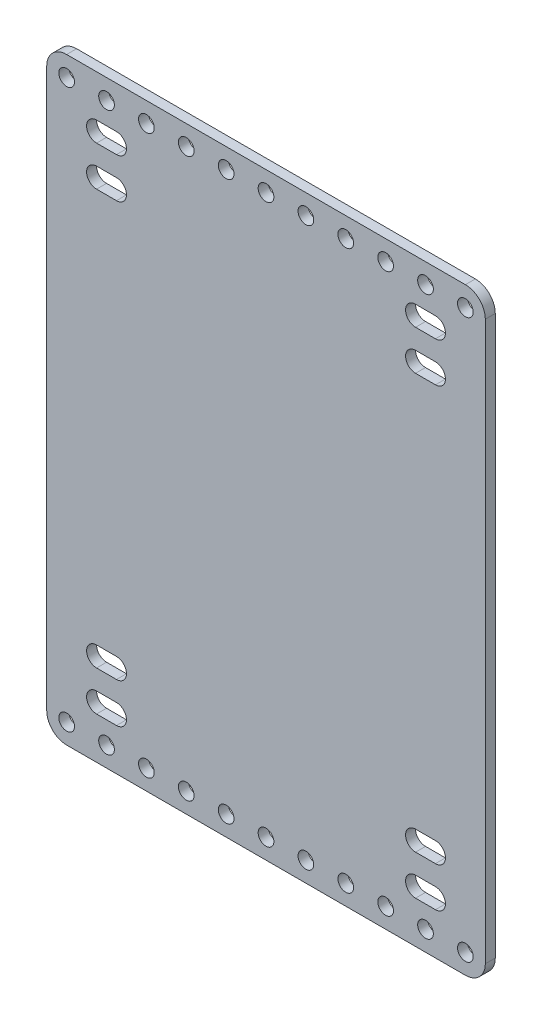
from build123d import *

# Parameters (mm, degrees)
BOSS_EXTRUDE1_DEPTH = 3.175
SKETCH3_R           = 2.5
CUT_EXTRUDE2_DEPTH  = 452.989575421
CUT_EXTRUDE3_DEPTH  = 452.989575421


with BuildPart() as part:
    # Sketch1 → Boss-Extrude1 (new body)
    with BuildSketch(Plane.XY):
        with BuildLine():
            Line((-367.50625, 254), (-240.50625, 254))
            ThreePointArc((-240.50625, 254), (-236.016121939, 252.140128061), (-234.15625, 247.65))
            Line((-234.15625, 247.65), (-234.15625, 69.85))
            ThreePointArc((-234.15625, 69.85), (-236.016121939, 65.359871939), (-240.50625, 63.5))
            Line((-240.50625, 63.5), (-367.50625, 63.5))
            ThreePointArc((-367.50625, 63.5), (-371.996378061, 65.359871939), (-373.85625, 69.85))
            Line((-373.85625, 69.85), (-373.85625, 247.65))
            ThreePointArc((-373.85625, 247.65), (-371.996378061, 252.140128061), (-367.50625, 254))
        make_face()
    extrude(amount=BOSS_EXTRUDE1_DEPTH)

    # Sketch3 → Cut-Extrude2 (cut, through all)
    with BuildSketch(Plane.XY.offset(3.175)):
        with Locations((-367.50625, 247.65)):
            Circle(SKETCH3_R)
        with Locations((-367.50625, 69.85)):
            Circle(SKETCH3_R)
        with Locations((-354.80625, 247.65)):
            Circle(SKETCH3_R)
        with Locations((-354.80625, 69.85)):
            Circle(SKETCH3_R)
        with Locations((-342.10625, 247.65)):
            Circle(SKETCH3_R)
        with Locations((-342.10625, 69.85)):
            Circle(SKETCH3_R)
        with Locations((-329.40625, 247.65)):
            Circle(SKETCH3_R)
        with Locations((-329.40625, 69.85)):
            Circle(SKETCH3_R)
        with Locations((-316.70625, 247.65)):
            Circle(SKETCH3_R)
        with Locations((-316.70625, 69.85)):
            Circle(SKETCH3_R)
        with Locations((-304.00625, 247.65)):
            Circle(SKETCH3_R)
        with Locations((-304.00625, 69.85)):
            Circle(SKETCH3_R)
        with Locations((-291.30625, 247.65)):
            Circle(SKETCH3_R)
        with Locations((-291.30625, 69.85)):
            Circle(SKETCH3_R)
        with Locations((-278.60625, 247.65)):
            Circle(SKETCH3_R)
        with Locations((-278.60625, 69.85)):
            Circle(SKETCH3_R)
        with Locations((-265.90625, 247.65)):
            Circle(SKETCH3_R)
        with Locations((-265.90625, 69.85)):
            Circle(SKETCH3_R)
        with Locations((-253.20625, 247.65)):
            Circle(SKETCH3_R)
        with Locations((-253.20625, 69.85)):
            Circle(SKETCH3_R)
        with Locations((-240.50625, 247.65)):
            Circle(SKETCH3_R)
        with Locations((-240.50625, 69.85)):
            Circle(SKETCH3_R)
    extrude(amount=-CUT_EXTRUDE2_DEPTH, mode=Mode.SUBTRACT)

    # Sketch4 → Cut-Extrude3 (cut, through all)
    with BuildSketch(Plane.XY.offset(3.175)):
        with BuildLine():
            Line((-351.63125, 240.665), (-357.98125, 240.665))
            ThreePointArc((-357.98125, 240.665), (-361.15625, 237.49), (-357.98125, 234.315))
            Line((-357.98125, 234.315), (-351.63125, 234.315))
            ThreePointArc((-351.63125, 234.315), (-348.45625, 237.49), (-351.63125, 240.665))
        make_face()
        with BuildLine():
            Line((-351.63125, 227.965), (-357.98125, 227.965))
            ThreePointArc((-357.98125, 227.965), (-361.15625, 224.79), (-357.98125, 221.615))
            Line((-357.98125, 221.615), (-351.63125, 221.615))
            ThreePointArc((-351.63125, 221.615), (-348.45625, 224.79), (-351.63125, 227.965))
        make_face()
        with BuildLine():
            ThreePointArc((-250.03125, 234.315), (-246.85625, 237.49), (-250.03125, 240.665))
            Line((-250.03125, 240.665), (-256.38125, 240.665))
            ThreePointArc((-256.38125, 240.665), (-259.55625, 237.49), (-256.38125, 234.315))
            Line((-256.38125, 234.315), (-250.03125, 234.315))
        make_face()
        with BuildLine():
            ThreePointArc((-250.03125, 221.615), (-246.85625, 224.79), (-250.03125, 227.965))
            Line((-250.03125, 227.965), (-256.38125, 227.965))
            ThreePointArc((-256.38125, 227.965), (-259.55625, 224.79), (-256.38125, 221.615))
            Line((-256.38125, 221.615), (-250.03125, 221.615))
        make_face()
        with BuildLine():
            Line((-256.38125, 89.535), (-250.03125, 89.535))
            ThreePointArc((-250.03125, 89.535), (-246.85625, 92.71), (-250.03125, 95.885))
            Line((-250.03125, 95.885), (-256.38125, 95.885))
            ThreePointArc((-256.38125, 95.885), (-259.55625, 92.71), (-256.38125, 89.535))
        make_face()
        with BuildLine():
            Line((-256.38125, 76.835), (-250.03125, 76.835))
            ThreePointArc((-250.03125, 76.835), (-246.85625, 80.01), (-250.03125, 83.185))
            Line((-250.03125, 83.185), (-256.38125, 83.185))
            ThreePointArc((-256.38125, 83.185), (-259.55625, 80.01), (-256.38125, 76.835))
        make_face()
        with BuildLine():
            ThreePointArc((-357.98125, 95.885), (-361.15625, 92.71), (-357.98125, 89.535))
            Line((-357.98125, 89.535), (-351.63125, 89.535))
            ThreePointArc((-351.63125, 89.535), (-348.45625, 92.71), (-351.63125, 95.885))
            Line((-351.63125, 95.885), (-357.98125, 95.885))
        make_face()
        with BuildLine():
            ThreePointArc((-357.98125, 83.185), (-361.15625, 80.01), (-357.98125, 76.835))
            Line((-357.98125, 76.835), (-351.63125, 76.835))
            ThreePointArc((-351.63125, 76.835), (-348.45625, 80.01), (-351.63125, 83.185))
            Line((-351.63125, 83.185), (-357.98125, 83.185))
        make_face()
    extrude(amount=-CUT_EXTRUDE3_DEPTH, mode=Mode.SUBTRACT)


solid = part.part
